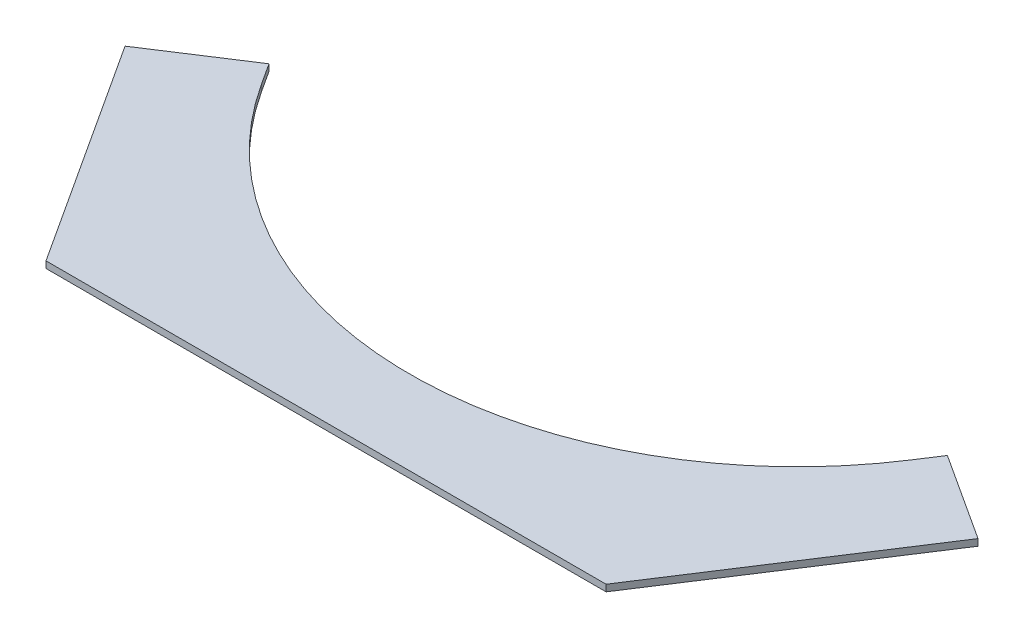
from build123d import *

# Parameters (mm, degrees)
BOSS_EXTRUDE1_DEPTH = 6.35


with BuildPart() as part:
    # Sketch1 → Boss-Extrude1 (new body)
    with BuildSketch(Plane(origin=(0, 0, 0), x_dir=(1, 0, 0), z_dir=(0, 1, 0))):
        with BuildLine():
            Line((0, 0), (534.9068, 0))
            Line((534.9068, 0), (674.758176597, 215.352234963))
            Line((674.758176597, 215.352234963), (591.419398393, 269.473070336))
            Line((591.419398393, 269.473070336), (577.803422518, 248.506306138))
            ThreePointArc((577.803422518, 248.506306138), (267.4534, 79.999992529), (-42.896622518, 248.506306138))
            Line((-42.896622518, 248.506306138), (-56.512598393, 269.473070336))
            Line((-56.512598393, 269.473070336), (-139.851376597, 215.352234963))
            Line((-139.851376597, 215.352234963), (0, 0))
        make_face()
    extrude(amount=BOSS_EXTRUDE1_DEPTH)


solid = part.part
